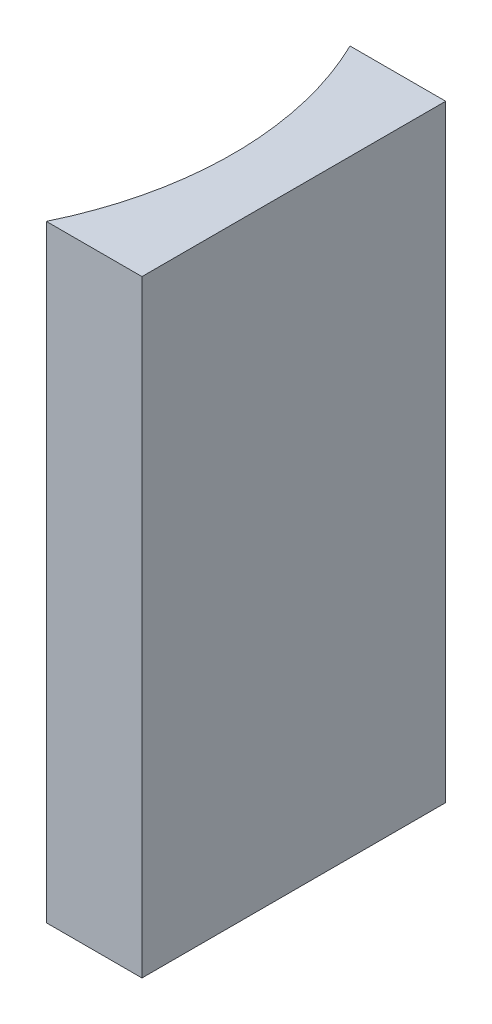
from build123d import *

# Parameters (mm, degrees)
EXTRUDE_1_DEPTH = 20


with BuildPart() as part:
    # 草图1 → 凸台-拉伸1 (new body)
    with BuildSketch(Plane(origin=(0, 0, 0), x_dir=(1, 0, 0), z_dir=(0, 1, 0))):
        with BuildLine():
            Line((0, 0), (0, -10))
            Line((0, -10), (-3.149393222, -10))
            ThreePointArc((-3.149393222, -10), (-2, -5), (-3.149393222, 0))
            Line((-3.149393222, 0), (0, 0))
        make_face()
    extrude(amount=EXTRUDE_1_DEPTH)


solid = part.part
